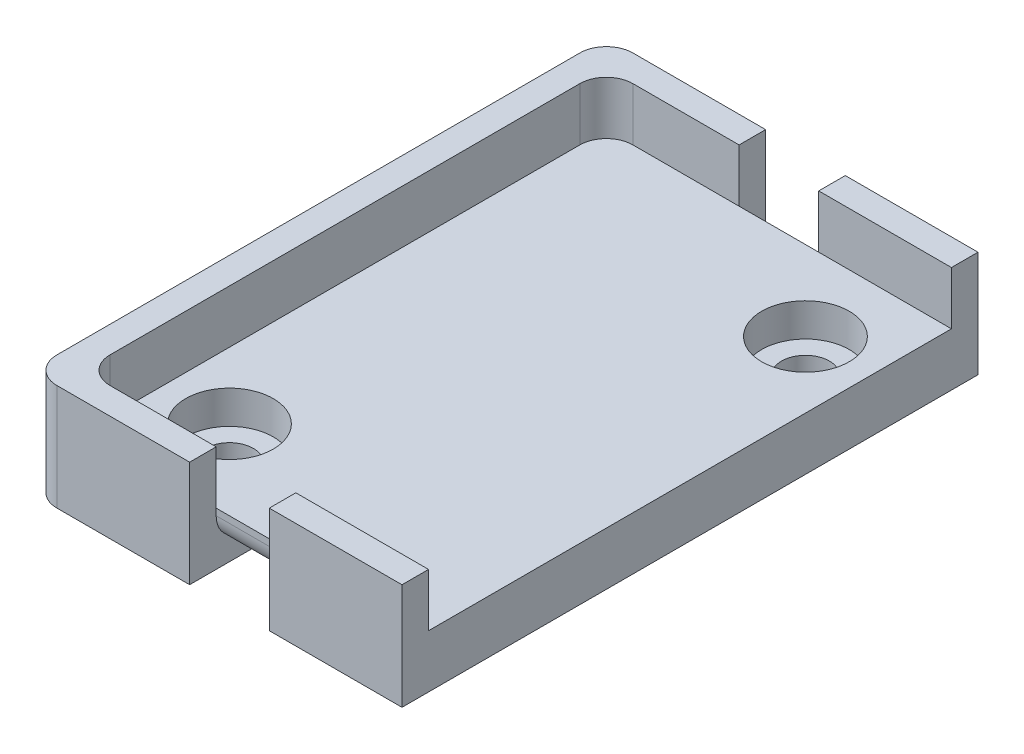
from build123d import *

# Parameters (mm, degrees)
SKETCH1_W           = 12.7
SKETCH1_H           = 50.038
SKETCH1_R           = 4.191
SKETCH1_R_2         = 2.286
SKETCH1_H_2         = 2.54
BOSS_EXTRUDE1_DEPTH = 1.905
BOSS_EXTRUDE3_START = 1.905
SKETCH1_3_W         = 7.62
SKETCH1_3_H         = 50.038
SKETCH1_3_W_2       = 12.7
SKETCH1_3_R         = 4.191
SKETCH1_3_H_2       = 2.54
BOSS_EXTRUDE3_DEPTH = 3.175
BOSS_EXTRUDE4_START = 5.08
SKETCH1_4_W         = 12.7
SKETCH1_4_H         = 2.54
BOSS_EXTRUDE4_DEPTH = 5.08
FILLET1_R           = 2.54


with BuildPart() as part:
    # Sketch1 → Boss-Extrude1 (new body)
    with BuildSketch(Plane(origin=(0, 0, 0), x_dir=(1, 0, 0), z_dir=(0, 1, 0))):
        with Locations((6.35, 25.019)):
            Rectangle(SKETCH1_W, SKETCH1_H)
        with Locations((6.35, 7.62)):
            Circle(SKETCH1_R, mode=Mode.SUBTRACT)
        with Locations((26.67, 25.019)):
            Rectangle(SKETCH1_W, SKETCH1_H)
        with Locations((26.67, 42.418)):
            Circle(SKETCH1_R, mode=Mode.SUBTRACT)
        with Locations((6.35, 7.62)):
            Circle(SKETCH1_R)
        with Locations((6.35, 7.62)):
            Circle(SKETCH1_R_2, mode=Mode.SUBTRACT)
        with Locations((26.67, 42.418)):
            Circle(SKETCH1_R)
        with Locations((26.67, 42.418)):
            Circle(SKETCH1_R_2, mode=Mode.SUBTRACT)
        Polygon((12.7, 0), (0, 0), (0, 50.038), (12.7, 50.038), (12.7, 52.578), (-2.54, 52.578), (-2.54, -2.54), (12.7, -2.54), align=None)
        with Locations((26.67, 51.308)):
            Rectangle(SKETCH1_W, SKETCH1_H_2)
        with Locations((26.67, -1.27)):
            Rectangle(SKETCH1_W, SKETCH1_H_2)
    extrude(amount=BOSS_EXTRUDE1_DEPTH)

    # Sketch1_3 → Boss-Extrude3 (add)
    with BuildSketch(Plane(origin=(0, 0, 0), x_dir=(1, 0, 0), z_dir=(0, 1, 0)).offset(BOSS_EXTRUDE3_START)):
        with Locations((16.51, 25.019)):
            Rectangle(SKETCH1_3_W, SKETCH1_3_H)
        with Locations((6.35, 25.019)):
            Rectangle(SKETCH1_3_W_2, SKETCH1_3_H)
        with Locations((6.35, 7.62)):
            Circle(SKETCH1_3_R, mode=Mode.SUBTRACT)
        with Locations((26.67, 25.019)):
            Rectangle(SKETCH1_3_W_2, SKETCH1_3_H)
        with Locations((26.67, 42.418)):
            Circle(SKETCH1_3_R, mode=Mode.SUBTRACT)
        Polygon((12.7, 0), (0, 0), (0, 50.038), (12.7, 50.038), (12.7, 52.578), (-2.54, 52.578), (-2.54, -2.54), (12.7, -2.54), align=None)
        with Locations((26.67, -1.27)):
            Rectangle(SKETCH1_3_W_2, SKETCH1_3_H_2)
        with Locations((26.67, 51.308)):
            Rectangle(SKETCH1_3_W_2, SKETCH1_3_H_2)
    extrude(amount=BOSS_EXTRUDE3_DEPTH)

    # Sketch1_4 → Boss-Extrude4 (add)
    with BuildSketch(Plane(origin=(0, 0, 0), x_dir=(1, 0, 0), z_dir=(0, 1, 0)).offset(BOSS_EXTRUDE4_START)):
        Polygon((12.7, 0), (0, 0), (0, 50.038), (12.7, 50.038), (12.7, 52.578), (-2.54, 52.578), (-2.54, -2.54), (12.7, -2.54), align=None)
        with Locations((26.67, -1.27)):
            Rectangle(SKETCH1_4_W, SKETCH1_4_H)
        with Locations((26.67, 51.308)):
            Rectangle(SKETCH1_4_W, SKETCH1_4_H)
    extrude(amount=BOSS_EXTRUDE4_DEPTH)

    # Fillet1
    fillet1_edges = [part.edges().sort_by_distance(p)[0] for p in [
        (0, 7.62, -50.038),
        (0, 7.62, 0),
        (-2.54, 5.08, -52.578),
        (-2.54, 5.08, 2.54),
        (16.51, 1.905, -50.038),
        (16.51, 1.905, 0),
    ]]
    fillet(fillet1_edges, radius=FILLET1_R)


solid = part.part
